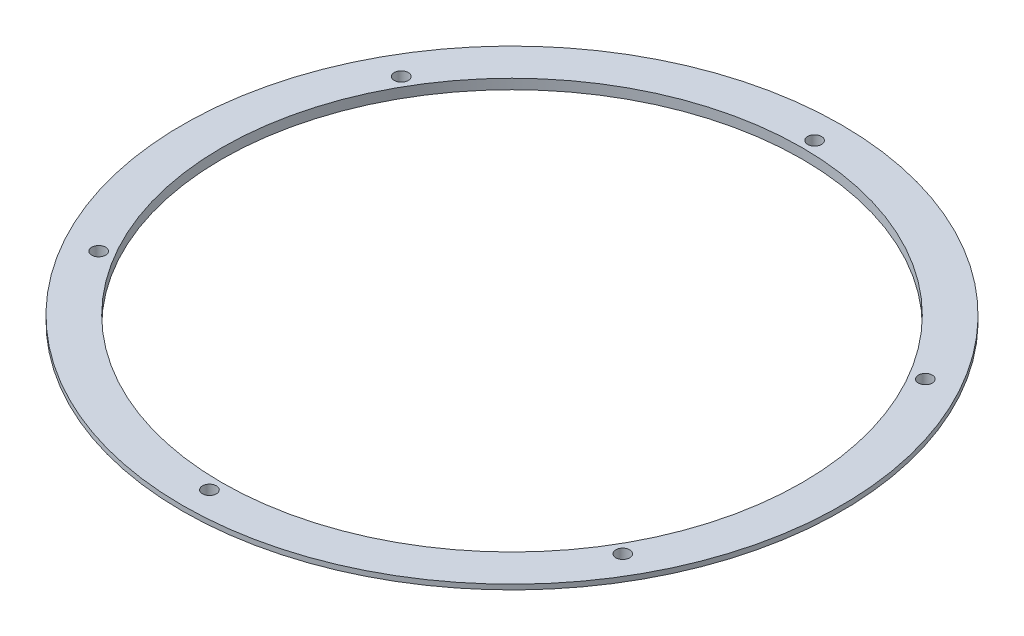
from build123d import *

# Parameters (mm, degrees)
SKETCH1_R           = 160.85
SKETCH1_R_2         = 3.556
SKETCH1_R_3         = 148.15
BOSS_EXTRUDE1_DEPTH = 5.08
SKETCH2_R           = 168.275
SKETCH2_R_2         = 160.85
BOSS_EXTRUDE2_DEPTH = 2.54


with BuildPart() as part:
    # Sketch1 → Boss-Extrude1 (new body)
    with BuildSketch(Plane(origin=(0, 0, 0), x_dir=(1, 0, 0), z_dir=(0, 1, 0))):
        Circle(SKETCH1_R)
        with Locations((0, 154.5)):
            Circle(SKETCH1_R_2, mode=Mode.SUBTRACT)
        with Locations((133.800924885, 77.25)):
            Circle(SKETCH1_R_2, mode=Mode.SUBTRACT)
        with Locations((133.800924885, -77.25)):
            Circle(SKETCH1_R_2, mode=Mode.SUBTRACT)
        with Locations((0, -154.5)):
            Circle(SKETCH1_R_2, mode=Mode.SUBTRACT)
        with Locations((-133.800924885, -77.25)):
            Circle(SKETCH1_R_2, mode=Mode.SUBTRACT)
        with Locations((-133.800924885, 77.25)):
            Circle(SKETCH1_R_2, mode=Mode.SUBTRACT)
        Circle(SKETCH1_R_3, mode=Mode.SUBTRACT)
    extrude(amount=BOSS_EXTRUDE1_DEPTH)

    # Sketch2 → Boss-Extrude2 (add)
    with BuildSketch(Plane(origin=(0, 5.08, 0), x_dir=(1, 0, 0), z_dir=(0, 1, 0))):
        Circle(SKETCH2_R)
        Circle(SKETCH2_R_2, mode=Mode.SUBTRACT)
    extrude(amount=-BOSS_EXTRUDE2_DEPTH)


solid = part.part
